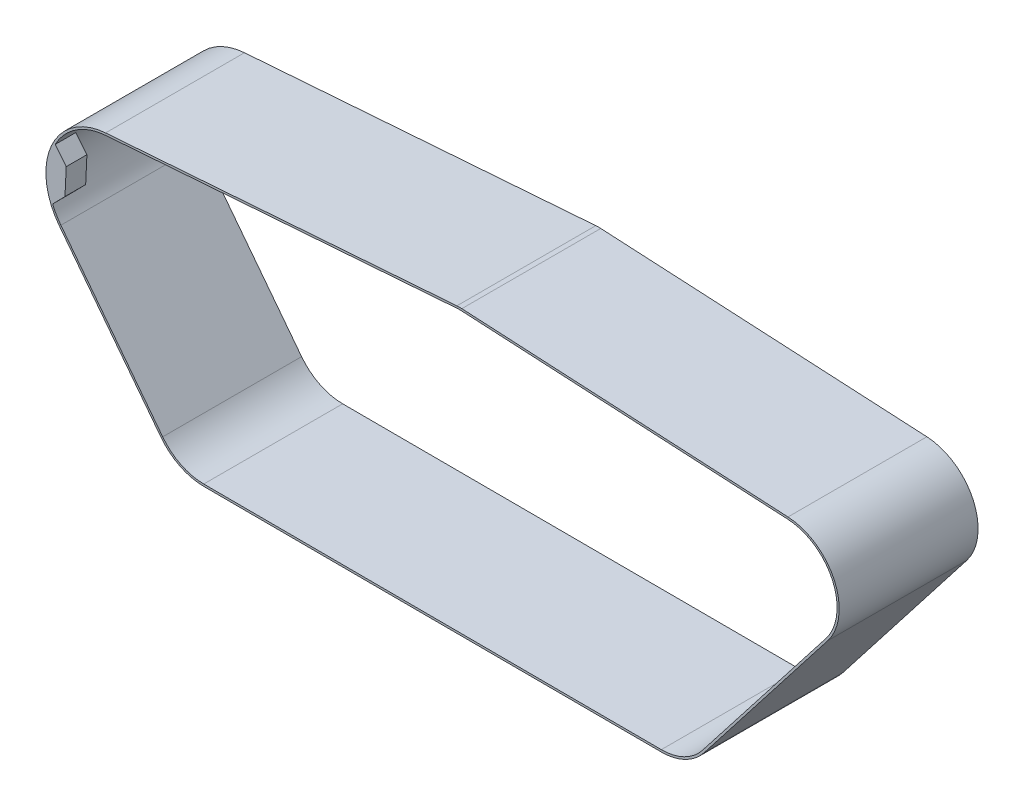
from build123d import *

# Parameters (mm, degrees)
EXTRUDE_THIN1_DEPTH = 23.5
BOSS_EXTRUDE1_DEPTH = 7


with BuildPart() as part:
    # Sketch2 → Extrude-Thin1 (new, symmetric)
    with BuildSketch(Plane.XY):
        with BuildLine():
            Line((17.163468236, -58.085931667), (-17.281893756, -13.288195823))
            ThreePointArc((-17.281893756, -13.288195823), (-19.897637951, 8.906402414), (-1.60242719, 21.741026358))
            Line((-1.60242719, 21.741026358), (117.263507159, 30.502066523))
            ThreePointArc((117.263507159, 30.502066523), (118.105083127, 30.537349971), (118.94720479, 30.519290718))
            Line((118.94720479, 30.519290718), (229.299625502, 24.652631518))
            ThreePointArc((229.299625502, 24.652631518), (244.976573908, 13.975728829), (242.768549107, -4.862731534))
            Line((242.768549107, -4.862731534), (200.935093877, -58.602091631))
            ThreePointArc((200.935093877, -58.602091631), (194.508519277, -63.812915391), (186.443863356, -65.660852138))
            Line((186.443863356, -65.660852138), (31.619949002, -65.231091278))
            ThreePointArc((31.619949002, -65.231091278), (23.562249738, -63.336718399), (17.163468236, -58.085931667))
        make_face()
        with BuildLine():
            Line((17.71839143, -57.65924648), (-16.726970562, -12.861510636))
            ThreePointArc((-16.726970562, -12.861510636), (-19.258722971, 8.620417015), (-1.550973106, 21.042920007))
            Line((-1.550973106, 21.042920007), (117.314961243, 29.803960172))
            ThreePointArc((117.314961243, 29.803960172), (118.112243739, 29.837386596), (118.910043209, 29.820277831))
            Line((118.910043209, 29.820277831), (229.262463921, 23.95361863))
            ThreePointArc((229.262463921, 23.95361863), (244.339747634, 13.685122055), (242.216182798, -4.432741463))
            Line((242.216182798, -4.432741463), (200.382727568, -58.17210156))
            ThreePointArc((200.382727568, -58.17210156), (194.201978227, -63.183604192), (186.445806412, -64.960854834))
            Line((186.445806412, -64.960854834), (31.621892057, -64.531093975))
            ThreePointArc((31.621892057, -64.531093975), (23.872410798, -62.709183447), (17.71839143, -57.65924648))
        make_face(mode=Mode.SUBTRACT)
    extrude(amount=EXTRUDE_THIN1_DEPTH, both=True)

    # Sketch3 → Boss-Extrude1 (add)
    with BuildSketch(Plane.XY.offset(23.5)):
        with BuildLine():
            Line((-15.342607214, -3.774175921), (-14.921356346, 5.195490812))
            Line((-14.921356346, 5.195490812), (-18.814600986, 9.982348011))
            Line((-18.814600986, 9.982348011), (-19.366834284, 10.008283061))
            ThreePointArc((-19.366834284, 10.008283061), (-21.78121341, 0.904843849), (-20.130207607, -8.367481205))
            Line((-20.130207607, -8.367481205), (-19.667345501, -8.175084284))
            Line((-19.667345501, -8.175084284), (-15.342607214, -3.774175921))
        make_face()
    extrude(amount=-BOSS_EXTRUDE1_DEPTH)


solid = part.part
